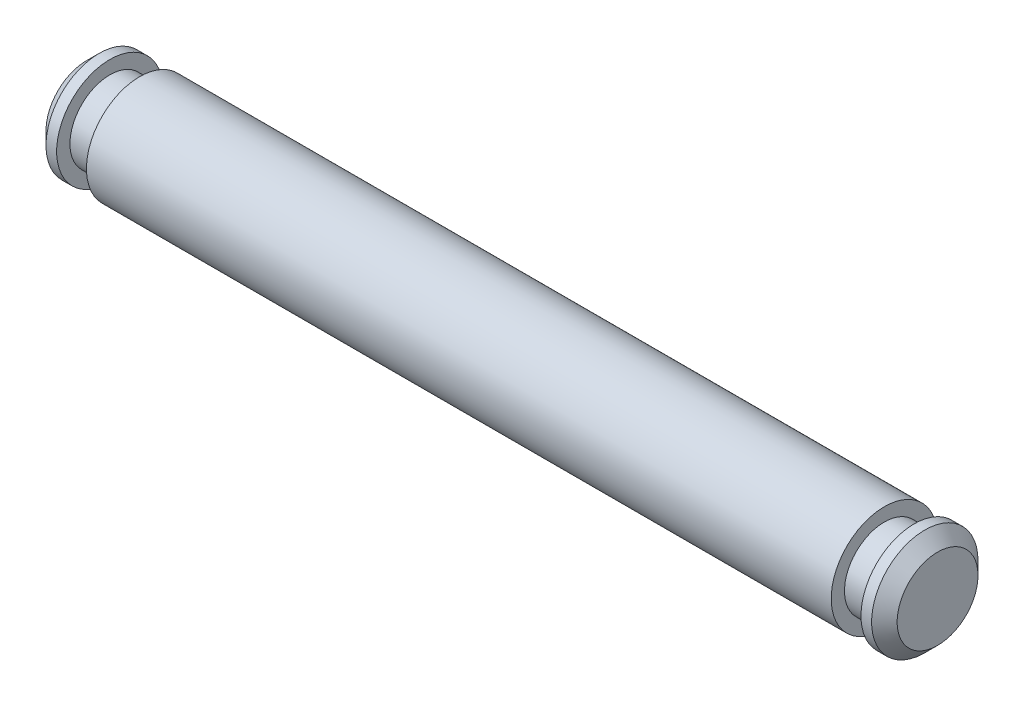
from build123d import *


with BuildPart() as part:
    # Sketch1 → Revolve1 (revolve)
    with BuildSketch(Plane.XY):
        Polygon((0, 0), (50.8, 0), (50.8, 2.413), (50.038, 3.175), (49.403, 3.175), (49.403, 2.38125), (47.625, 2.38125), (47.625, 3.175), (3.175, 3.175), (3.175, 2.38125), (1.397, 2.38125), (1.397, 3.175), (0.762, 3.175), (0, 2.413), align=None)
    revolve(axis=Axis((0, 0, 0), (-1, 0, 0)))


solid = part.part
